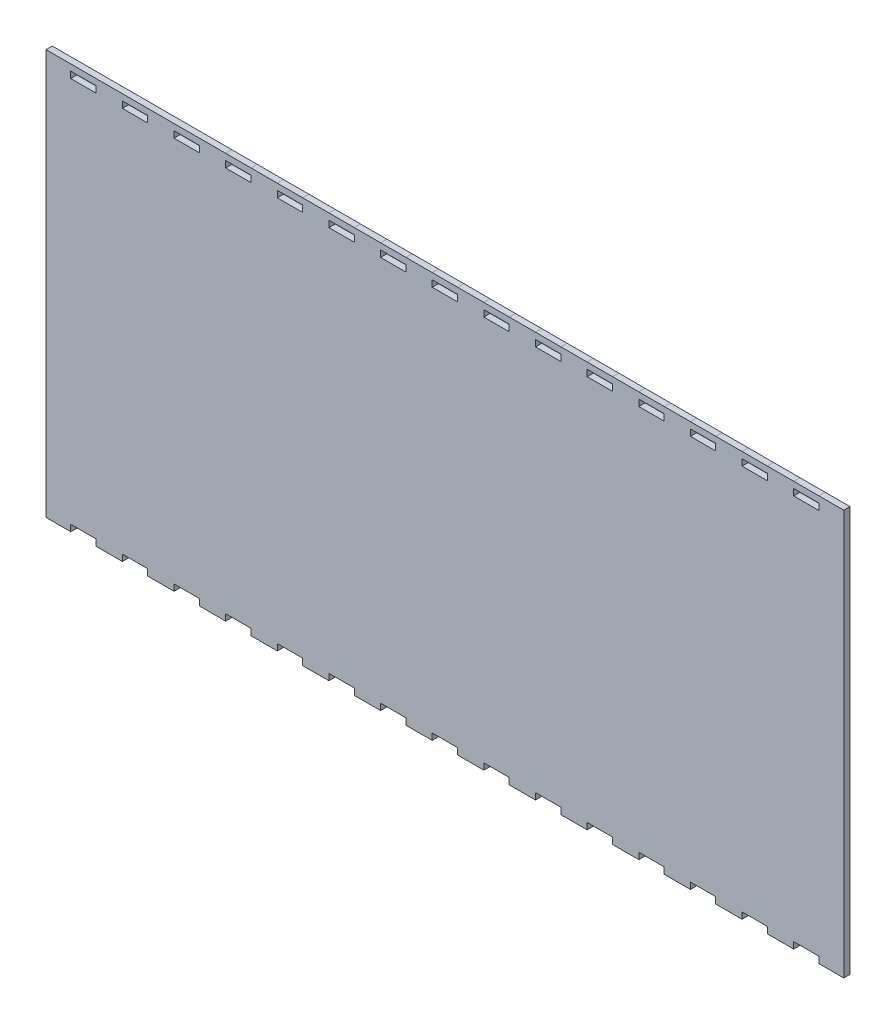
from build123d import *

# Parameters (mm, degrees)
BOSS_EXTRUDE1_DEPTH      = 3.175
SKETCH2_W                = 13.407142857
SKETCH2_H                = 3.175
SKETCH2_W_2              = 12.6000002
SKETCH2_W_3              = 13.407142858
SKETCH2_W_4              = 12.6
BOSS_EXTRUDE3_DEPTH      = 3.175
BOSS_EXTRUDE3_DEPTH_BACK = 0.635
SKETCH3_W                = 3.175
SKETCH3_H                = 3.175
BOSS_EXTRUDE4_DEPTH      = 381.2


with BuildPart() as part:
    # Sketch1 → Boss-Extrude1 (new body)
    with BuildSketch(Plane.XY):
        Polygon((393.8, 203.2), (393.8, 199.925), (380.9, 199.925), (380.9, 203.2), (367.492857143, 203.2), (367.492857143, 199.925), (354.592857143, 199.925), (354.592857143, 203.2), (341.185714286, 203.2), (341.185714286, 199.925), (328.285714286, 199.925), (328.285714286, 203.2), (314.878571429, 203.2), (314.878571429, 199.925), (301.978571429, 199.925), (301.978571429, 203.2), (288.571428571, 203.2), (288.571428571, 199.925), (275.671428571, 199.925), (275.671428571, 203.2), (262.264285714, 203.2), (262.264285714, 199.925), (249.364285714, 199.925), (249.364285714, 203.2), (235.957142857, 203.2), (235.957142857, 199.925), (223.057142857, 199.925), (223.057142857, 203.2), (209.65, 203.2), (209.65, 199.925), (196.75, 199.925), (196.75, 203.2), (183.342857143, 203.2), (183.342857143, 199.925), (170.442857143, 199.925), (170.442857143, 203.2), (157.035714286, 203.2), (157.035714286, 199.925), (144.135714286, 199.925), (144.135714286, 203.2), (130.728571429, 203.2), (130.728571429, 199.925), (117.828571429, 199.925), (117.828571429, 203.2), (104.421428571, 203.2), (104.421428571, 199.925), (91.521428571, 199.925), (91.521428571, 203.2), (78.114285714, 203.2), (78.114285714, 199.925), (65.214285714, 199.925), (65.214285714, 203.2), (51.807142857, 203.2), (51.807142857, 199.925), (38.907142857, 199.925), (38.907142857, 203.2), (25.5, 203.2), (25.5, 199.925), (12.6, 199.925), (12.6000002, 203.2254), (0, 203.2254), (0, -0.0254), (12.6000002, -0.0254), (12.6, 3.275), (25.5, 3.275), (25.5, 0), (38.907142857, 0), (38.907142857, 3.275), (51.807142857, 3.275), (51.807142857, 0), (65.214285714, 0), (65.214285714, 3.275), (78.114285714, 3.275), (78.114285714, 0), (91.521428571, 0), (91.521428571, 3.275), (104.421428571, 3.275), (104.421428571, 0), (117.828571429, 0), (117.828571429, 3.275), (130.728571429, 3.275), (130.728571429, 0), (144.135714286, 0), (144.135714286, 3.275), (157.035714286, 3.275), (157.035714286, 0), (170.442857143, 0), (170.442857143, 3.275), (183.342857143, 3.275), (183.342857143, 0), (196.75, 0), (196.75, 3.275), (209.65, 3.275), (209.65, 0), (223.057142857, 0), (223.057142857, 3.275), (235.957142857, 3.275), (235.957142857, 0), (249.364285714, 0), (249.364285714, 3.275), (262.264285714, 3.275), (262.264285714, 0), (275.671428571, 0), (275.671428571, 3.275), (288.571428571, 3.275), (288.571428571, 0), (301.978571429, 0), (301.978571429, 3.275), (314.878571429, 3.275), (314.878571429, 0), (328.285714286, 0), (328.285714286, 3.275), (341.185714286, 3.275), (341.185714286, 0), (354.592857143, 0), (354.592857143, 3.275), (367.492857143, 3.275), (367.492857143, 0), (380.9, 0), (380.9, 3.275), (393.8, 3.275), (393.8, 0), (406.4, 0), (406.4, 203.2), align=None)
    extrude(amount=BOSS_EXTRUDE1_DEPTH)

    # Sketch2 → Boss-Extrude3 (add, two sides)
    with BuildSketch(Plane(origin=(0, 203.2254, 0), x_dir=(1, 0, 0), z_dir=(0, 1, 0))) as boss_extrude3_sk:
        with Locations((32.203571428, -1.5875)):
            Rectangle(SKETCH2_W, SKETCH2_H)
        with Locations((58.510714286, -1.5875)):
            Rectangle(SKETCH2_W, SKETCH2_H)
        with Locations((137.432142857, -1.5875)):
            Rectangle(SKETCH2_W, SKETCH2_H)
        with Locations((163.739285714, -1.5875)):
            Rectangle(SKETCH2_W, SKETCH2_H)
        with Locations((216.353571429, -1.5875)):
            Rectangle(SKETCH2_W, SKETCH2_H)
        with Locations((321.582142858, -1.5875)):
            Rectangle(SKETCH2_W, SKETCH2_H)
        with Locations((6.3000001, -1.5875)):
            Rectangle(SKETCH2_W_2, SKETCH2_H)
        with Locations((84.817857143, -1.5875)):
            Rectangle(SKETCH2_W, SKETCH2_H)
        with Locations((111.125, -1.5875)):
            Rectangle(SKETCH2_W_3, SKETCH2_H)
        with Locations((190.046428572, -1.5875)):
            Rectangle(SKETCH2_W, SKETCH2_H)
        with Locations((242.660714286, -1.5875)):
            Rectangle(SKETCH2_W, SKETCH2_H)
        with Locations((268.967857143, -1.5875)):
            Rectangle(SKETCH2_W, SKETCH2_H)
        with Locations((295.275, -1.5875)):
            Rectangle(SKETCH2_W_3, SKETCH2_H)
        with Locations((347.889285715, -1.5875)):
            Rectangle(SKETCH2_W, SKETCH2_H)
        with Locations((374.196428572, -1.5875)):
            Rectangle(SKETCH2_W, SKETCH2_H)
        with Locations((400.1, -1.5875)):
            Rectangle(SKETCH2_W_4, SKETCH2_H)
    extrude(amount=BOSS_EXTRUDE3_DEPTH)
    extrude(boss_extrude3_sk.sketch, amount=-BOSS_EXTRUDE3_DEPTH_BACK)

    # Sketch3 → Boss-Extrude4 (add)
    with BuildSketch(Plane(origin=(12.599987885, -7.64e-07, 0), x_dir=(0, 0, -1), z_dir=(1, -6.1e-08, 0))):
        with Locations((-1.5875, 204.812900764)):
            Rectangle(SKETCH3_W, SKETCH3_H)
    extrude(amount=BOSS_EXTRUDE4_DEPTH)


solid = part.part
